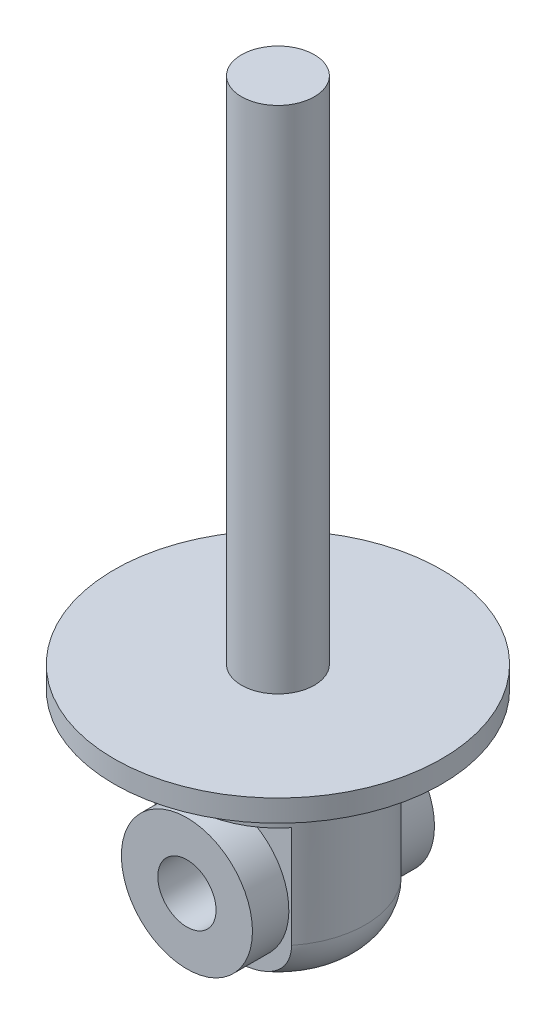
from build123d import *
from build123d.topology import SkipClean

# Parameters (mm, degrees)
SKETCH1_R               = 22.5
BOSS_EXTRUDE1_DEPTH     = 3
SKETCH2_R               = 5
BOSS_EXTRUDE2_DEPTH     = 70
SKETCH3_R               = 12
BOSS_EXTRUDE3_DEPTH     = 28
FILLET1_R               = 6
SKETCH4_W               = 13.909985693
SKETCH4_H               = 20
CUT_EXTRUDE1_DEPTH      = 80.633535649
CUT_EXTRUDE1_DEPTH_BACK = 80.633535649
SKETCH8_R               = 4
CUT_EXTRUDE3_DEPTH      = 83.068568892
SKETCH10_R              = 9
SKETCH10_R_2            = 4
BOSS_EXTRUDE5_DEPTH     = 12.5


with BuildPart() as part:
    # Sketch1 → Boss-Extrude1 (new body)
    with BuildSketch(Plane(origin=(0, 0, 0), x_dir=(1, 0, 0), z_dir=(0, 1, 0))):
        with Locations(Location((0, 0, 0), (0, 0, 270))):
            Circle(SKETCH1_R)
    extrude(amount=BOSS_EXTRUDE1_DEPTH)

    # Sketch2 → Boss-Extrude2 (add)
    with BuildSketch(Plane(origin=(0, 3, 0), x_dir=(1, 0, 0), z_dir=(0, 1, 0))):
        with Locations(Location((0, 0, 0), (0, 0, 270))):
            Circle(SKETCH2_R)
    extrude(amount=BOSS_EXTRUDE2_DEPTH)

    # Sketch3 → Boss-Extrude3 (add)
    with BuildSketch(Plane.XZ):
        with Locations(Location((0, 0, 0), (0, 0, 270))):
            Circle(SKETCH3_R)
    extrude(amount=BOSS_EXTRUDE3_DEPTH)

    # Fillet1
    fillet1_edges = [part.edges().sort_by_distance(p)[0] for p in [
        (0, -28, 12),
    ]]
    fillet(fillet1_edges, radius=FILLET1_R)

    # Sketch4 → Cut-Extrude1 (cut, two sides)
    with BuildSketch(Plane(origin=(0, 0, 0), x_dir=(0, 0, -1), z_dir=(1, 0, 0))) as cut_extrude1_sk:
        with Locations((14.454992847, -18)):
            Rectangle(SKETCH4_W, SKETCH4_H)
        with Locations((-14.454992847, -18)):
            Rectangle(SKETCH4_W, SKETCH4_H)
    extrude(amount=CUT_EXTRUDE1_DEPTH, mode=Mode.SUBTRACT)
    extrude(cut_extrude1_sk.sketch, amount=-CUT_EXTRUDE1_DEPTH_BACK, mode=Mode.SUBTRACT)

    # Sketch8 → Cut-Extrude3 (cut, through all)
    with BuildSketch(Plane(origin=(0, 0, -7.5), x_dir=(-1, 0, 0), z_dir=(0, 0, -1))):
        with Locations(Location((0, -18, 0), (0, 0, 90))):
            Circle(SKETCH8_R)
    extrude(amount=-CUT_EXTRUDE3_DEPTH, mode=Mode.SUBTRACT)

    # Sketch10 → Boss-Extrude5 (add, symmetric)
    with SkipClean():  # the faces are left unmerged after this step: merging them gives an invalid solid
        with BuildSketch(Plane.XY):
            with Locations(Location((0, -18, 0), (0, 0, 270))):
                Circle(SKETCH10_R)
            with Locations((0, -18)):
                Circle(SKETCH10_R_2, mode=Mode.SUBTRACT)
        extrude(amount=BOSS_EXTRUDE5_DEPTH, both=True)


solid = part.part
